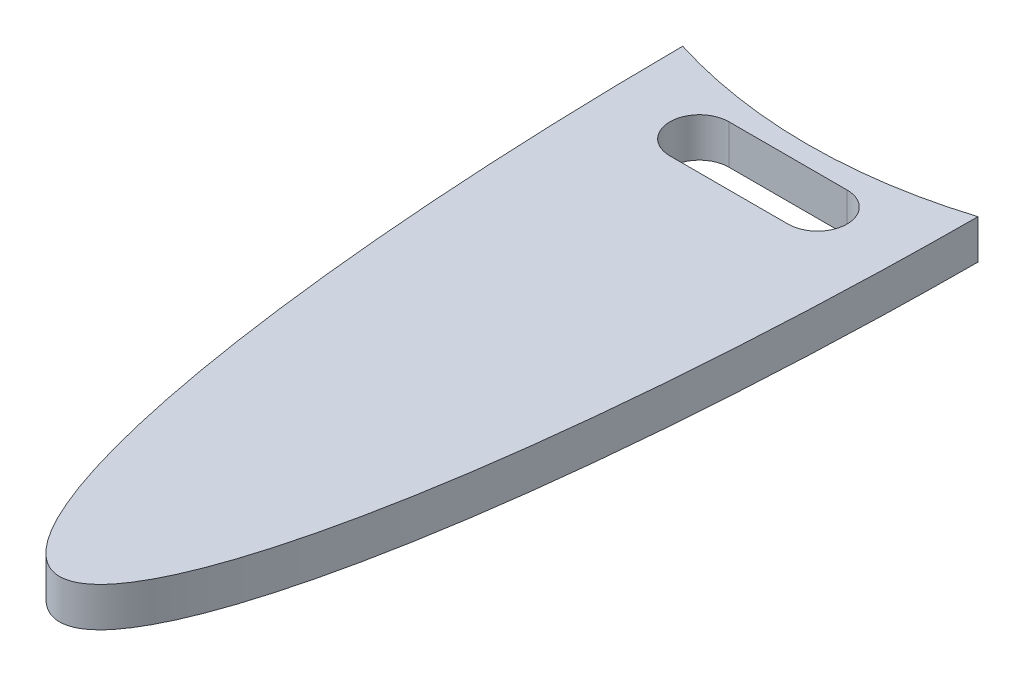
from build123d import *

# Parameters (mm, degrees)
BOSS_EXTRUDE1_DEPTH = 2.54
CUT_EXTRUDE1_DEPTH  = 3.5400001
SKETCH4_R           = 31.75
CUT_EXTRUDE2_DEPTH  = 3.5400001


with BuildPart() as part:
    # Sketch1 → Boss-Extrude1 (new body)
    with BuildSketch(Plane(origin=(0, 0, 0), x_dir=(1, 0, 0), z_dir=(0, 1, 0))):
        with BuildLine():
            Line((9.525, 0), (-9.525, 0))
            add(Edge.make_bspline(
                [(-9.525, 0), (-9.525, -50.8), (0, -50.8), (9.525, -50.8), (9.525, 0)],
                knots=[1.570796327, 1.570796327, 1.570796327, 3.141592654, 3.141592654, 4.71238898, 4.71238898, 4.71238898], degree=2, weights=[1, 0.707106781, 1, 0.707106781, 1]))
        make_face()
    extrude(amount=BOSS_EXTRUDE1_DEPTH)

    # Sketch3 → Cut-Extrude1 (cut, through all)
    with BuildSketch(Plane(origin=(0, 2.54, 0), x_dir=(1, 0, 0), z_dir=(0, 1, 0))):
        with BuildLine():
            Line((-3.81, -3.81), (3.81, -3.81))
            ThreePointArc((3.81, -3.81), (5.715, -5.715), (3.81, -7.62))
            Line((3.81, -7.62), (-3.81, -7.62))
            ThreePointArc((-3.81, -7.62), (-5.715, -5.715), (-3.81, -3.81))
        make_face()
    extrude(amount=-CUT_EXTRUDE1_DEPTH, mode=Mode.SUBTRACT)

    # Sketch4 → Cut-Extrude2 (cut, through all)
    with BuildSketch(Plane(origin=(0, 2.54, 0), x_dir=(1, 0, 0), z_dir=(0, 1, 0))):
        with Locations((0, 29.21)):
            Circle(SKETCH4_R)
    extrude(amount=-CUT_EXTRUDE2_DEPTH, mode=Mode.SUBTRACT)


solid = part.part
